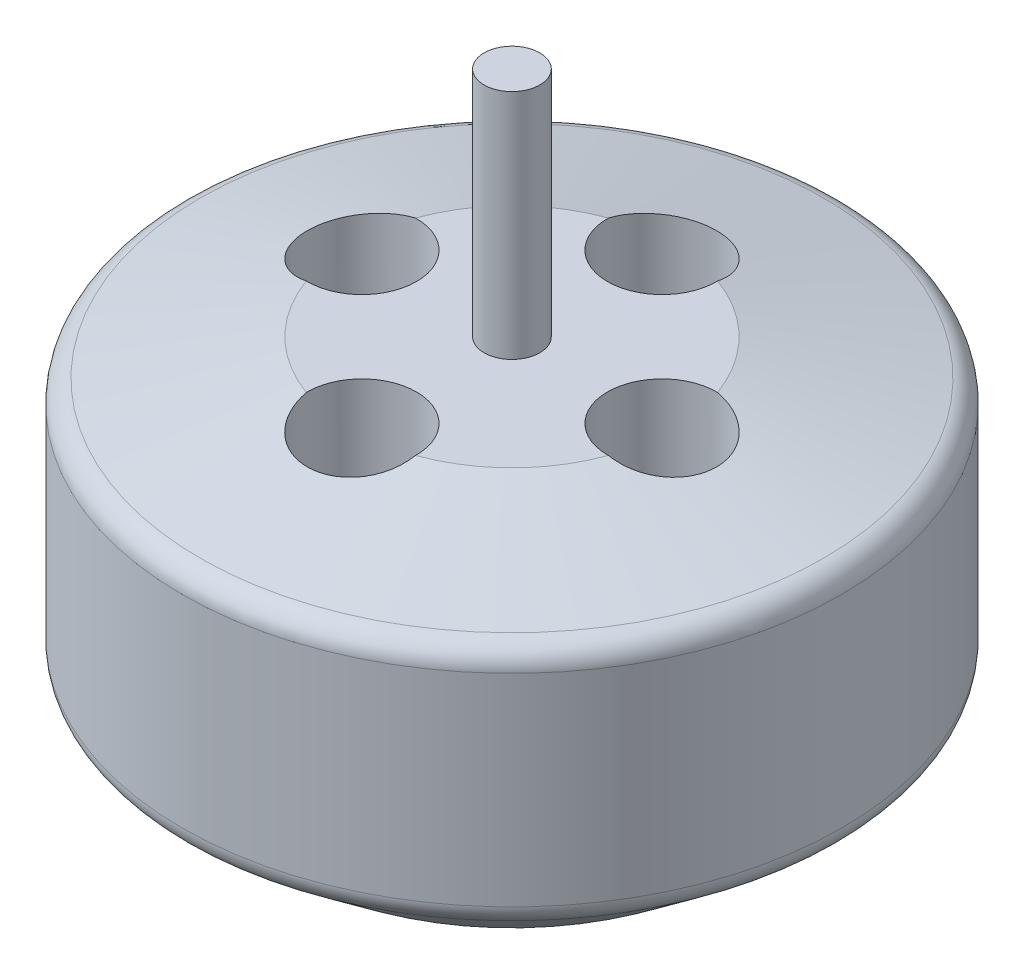
from build123d import *

# Parameters (mm, degrees)
SKETCH3_R          = 2.352290117
CUT_EXTRUDE1_DEPTH = 10
CIRPATTERN1_COUNT  = 4
FILLET1_R          = 1


with BuildPart() as part:
    # Sketch2 → Revolve1 (revolve)
    with BuildSketch(Plane.XY):
        Polygon((0, 9.231240755), (0, -15.768759245), (10, -15.768759245), (14.214231209, -12.495683607), (14.214231209, -2.495683607), (6.923362893, -0.768759245), (1.2, -0.768759245), (1.2, 9.231240755), align=None)
    revolve(axis=Axis((0, 9.231240755, 0), (0, -1, 0)))

    # Sketch3 → Cut-Extrude1 (cut)
    with BuildSketch(Plane(origin=(0, 4.615620377, 0), x_dir=(1, 0, 0), z_dir=(0, 1, 0))):
        with Locations((0, -6.470406052)):
            Circle(SKETCH3_R)
    cut_extrude1 = extrude(amount=-CUT_EXTRUDE1_DEPTH, mode=Mode.SUBTRACT)

    # CirPattern1: Cut-Extrude1 ×4 about axis
    cirpattern1_axis = Axis((0, 0, 0), (0, 1, 0))
    for i in range(1, CIRPATTERN1_COUNT):
        add(cut_extrude1.rotate(cirpattern1_axis, i * 360 / CIRPATTERN1_COUNT), mode=Mode.SUBTRACT)

    # Fillet1
    fillet1_edges = [part.edges().sort_by_distance(p)[0] for p in [
        (-14.214231209, -2.495683607, 0),
        (-14.214231209, -12.495683607, 0),
    ]]
    fillet(fillet1_edges, radius=FILLET1_R)


solid = part.part
